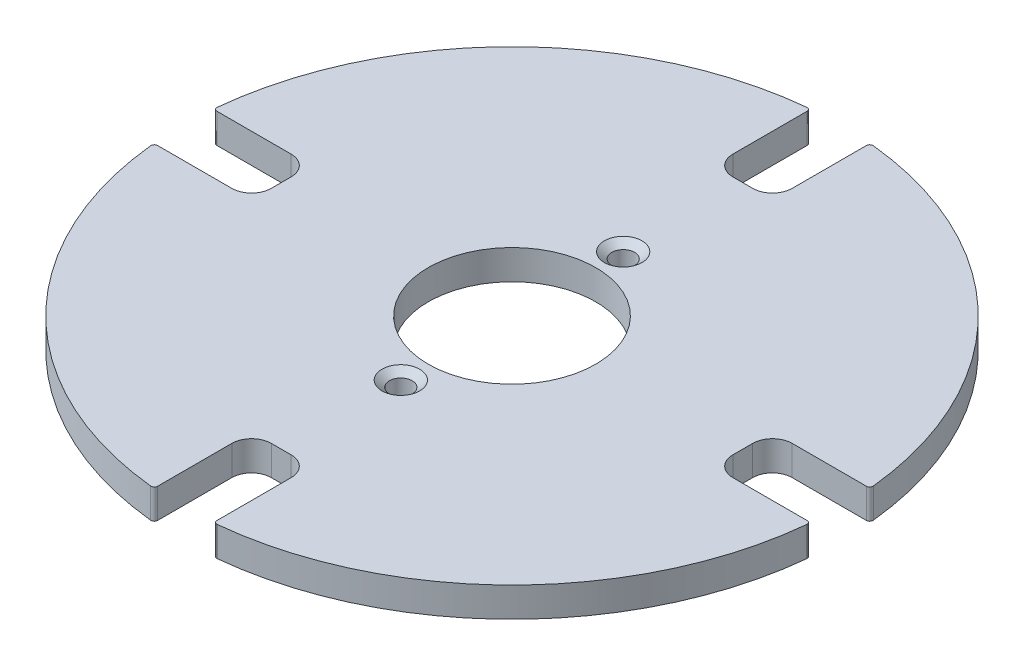
from build123d import *

# Parameters (mm, degrees)
SKETCH3_R                                         = 50
SKETCH3_R_2                                       = 12.7
BOSS_EXTRUDE4_DEPTH                               = 4.5
CUT_EXTRUDE18_DEPTH                               = 10
FILLET2_R                                         = 0.5
CSK_FOR_4_FLAT_HEAD_MACHINE_SCREW_100_D           = 3.4544
CSK_FOR_4_FLAT_HEAD_MACHINE_SCREW_100_CSINK_D     = 5.715
CSK_FOR_4_FLAT_HEAD_MACHINE_SCREW_100_CSINK_ANGLE = 100


with BuildPart() as part:
    # Sketch3 → Boss-Extrude4 (new body)
    with BuildSketch(Plane(origin=(0, 0, 0), x_dir=(1, 0, 0), z_dir=(0, 1, 0))):
        Circle(SKETCH3_R)
        Circle(SKETCH3_R_2, mode=Mode.SUBTRACT)
    extrude(amount=BOSS_EXTRUDE4_DEPTH)

    # Sketch6 → Cut-Extrude18 (cut)
    with BuildSketch(Plane(origin=(0, 0, 0), x_dir=(1, 0, 0), z_dir=(0, 1, 0))):
        with BuildLine():
            Line((-38, -4.5), (-65, -4.5))
            Line((-65, -4.5), (-65, 4.5))
            Line((-65, 4.5), (-38, 4.5))
            ThreePointArc((-38, 4.5), (-35.878679656, 3.621320344), (-35, 1.5))
            Line((-35, 1.5), (-35, -1.5))
            ThreePointArc((-35, -1.5), (-35.878679656, -3.621320344), (-38, -4.5))
        make_face()
        with BuildLine():
            Line((-4.5, 38), (-4.5, 65))
            Line((-4.5, 65), (4.5, 65))
            Line((4.5, 65), (4.5, 38))
            ThreePointArc((4.5, 38), (3.621320344, 35.878679656), (1.5, 35))
            Line((1.5, 35), (-1.5, 35))
            ThreePointArc((-1.5, 35), (-3.621320344, 35.878679656), (-4.5, 38))
        make_face()
        with BuildLine():
            Line((38, 4.5), (65, 4.5))
            Line((65, 4.5), (65, -4.5))
            Line((65, -4.5), (38, -4.5))
            ThreePointArc((38, -4.5), (35.878679656, -3.621320344), (35, -1.5))
            Line((35, -1.5), (35, 1.5))
            ThreePointArc((35, 1.5), (35.878679656, 3.621320344), (38, 4.5))
        make_face()
        with BuildLine():
            Line((4.5, -38), (4.5, -65))
            Line((4.5, -65), (-4.5, -65))
            Line((-4.5, -65), (-4.5, -38))
            ThreePointArc((-4.5, -38), (-3.621320344, -35.878679656), (-1.5, -35))
            Line((-1.5, -35), (1.5, -35))
            ThreePointArc((1.5, -35), (3.621320344, -35.878679656), (4.5, -38))
        make_face()
    extrude(amount=CUT_EXTRUDE18_DEPTH, mode=Mode.SUBTRACT)

    # Fillet2
    fillet2_edges = [part.edges().sort_by_distance(p)[0] for p in [
        (-49.797088268, 2.25, -4.5),
        (-49.797088268, 2.25, 4.5),
        (4.5, 2.25, -49.797088268),
        (-4.5, 2.25, -49.797088268),
        (49.797088268, 2.25, 4.5),
        (49.797088268, 2.25, -4.5),
        (-4.5, 2.25, 49.797088268),
        (4.5, 2.25, 49.797088268),
    ]]
    fillet(fillet2_edges, radius=FILLET2_R)

    # CSK for #4 Flat Head Machine Screw (100)1 (through all)
    with Locations(Plane(origin=(0, 4.5, 0), x_dir=(1, 0, 0), z_dir=(0, 1, 0))):
        with Locations((0, -16.862709614), (0, 16.862709614)):
            CounterSinkHole(CSK_FOR_4_FLAT_HEAD_MACHINE_SCREW_100_D / 2, CSK_FOR_4_FLAT_HEAD_MACHINE_SCREW_100_CSINK_D / 2, counter_sink_angle=CSK_FOR_4_FLAT_HEAD_MACHINE_SCREW_100_CSINK_ANGLE)


solid = part.part
